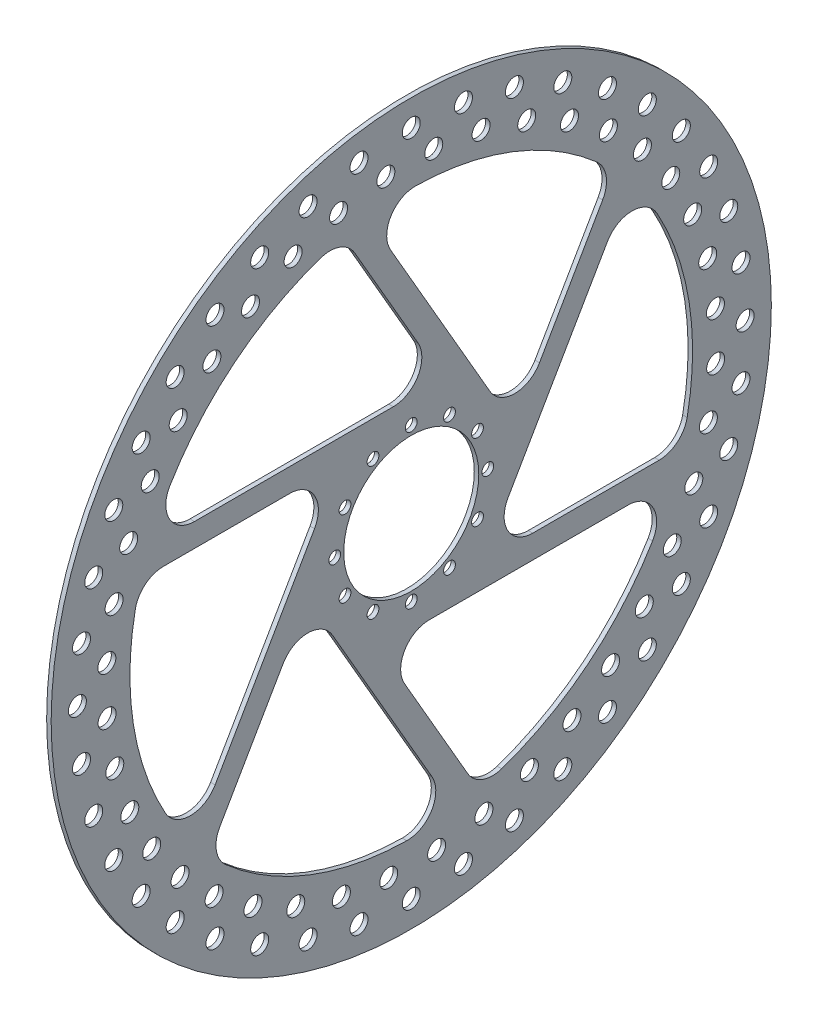
from build123d import *

# Parameters (mm, degrees)
SKETCH1_R           = 160
SKETCH1_R_2         = 4
SKETCH1_R_3         = 2.625
SKETCH1_R_4         = 30
BOSS_EXTRUDE1_DEPTH = 2
FILLET1_R           = 12.7


with BuildPart() as part:
    # Sketch1 → Boss-Extrude1 (new body)
    with BuildSketch(Plane(origin=(0, 0, 0), x_dir=(0, 0, -1), z_dir=(1, 0, 0))):
        Circle(SKETCH1_R)
        with BuildLine():
            Line((-30.068891187, 121.32955857), (14, 45))
            Line((14, 45), (-116.619037897, 45))
            ThreePointArc((-116.619037897, 45), (-82.679426175, 93.750266599), (-30.068891187, 121.32955857))
        make_face(mode=Mode.SUBTRACT)
        with BuildLine():
            Line((45.97114317, 10.375644347), (-19.338375778, 123.495049384))
            ThreePointArc((-19.338375778, 123.495049384), (39.850399399, 118.477616737), (90.040034358, 86.705202917))
            Line((90.040034358, 86.705202917), (45.97114317, 10.375644347))
        make_face(mode=Mode.SUBTRACT)
        with BuildLine():
            Line((31.97114317, -34.624355653), (97.280662119, 78.495049384))
            ThreePointArc((97.280662119, 78.495049384), (122.529825574, 24.727350138), (120.108925545, -34.624355653))
            Line((120.108925545, -34.624355653), (31.97114317, -34.624355653))
        make_face(mode=Mode.SUBTRACT)
        with BuildLine():
            Line((-14, -45), (116.619037897, -45))
            ThreePointArc((116.619037897, -45), (82.679426175, -93.750266599), (30.068891187, -121.32955857))
            Line((30.068891187, -121.32955857), (-14, -45))
        make_face(mode=Mode.SUBTRACT)
        with BuildLine():
            Line((-45.97114317, -10.375644347), (19.338375778, -123.495049384))
            ThreePointArc((19.338375778, -123.495049384), (-39.850399399, -118.477616737), (-90.040034358, -86.705202917))
            Line((-90.040034358, -86.705202917), (-45.97114317, -10.375644347))
        make_face(mode=Mode.SUBTRACT)
        with BuildLine():
            Line((-31.97114317, 34.624355653), (-97.280662119, -78.495049384))
            ThreePointArc((-97.280662119, -78.495049384), (-122.529825574, -24.727350138), (-120.108925545, 34.624355653))
            Line((-120.108925545, 34.624355653), (-31.97114317, 34.624355653))
        make_face(mode=Mode.SUBTRACT)
        with Locations((-87.188145757, -120.004187499)):
            Circle(SKETCH1_R_2, mode=Mode.SUBTRACT)
        with Locations((-120.004187499, -87.188145757)):
            Circle(SKETCH1_R_2, mode=Mode.SUBTRACT)
        with Locations((-104.887505876, -104.887505876)):
            Circle(SKETCH1_R_2, mode=Mode.SUBTRACT)
        with Locations((-87.590662868, -103.545188607)):
            Circle(SKETCH1_R_2, mode=Mode.SUBTRACT)
        with Locations((-102.710312647, -88.568177023)):
            Circle(SKETCH1_R_2, mode=Mode.SUBTRACT)
        with Locations((-45.837520832, -141.07338325)):
            Circle(SKETCH1_R_2, mode=Mode.SUBTRACT)
        with Locations((-67.341924128, -132.165967755)):
            Circle(SKETCH1_R_2, mode=Mode.SUBTRACT)
        with Locations((-51.306447722, -125.54432973)):
            Circle(SKETCH1_R_2, mode=Mode.SUBTRACT)
        with Locations((-23.204445648, -146.507103855)):
            Circle(SKETCH1_R_2, mode=Mode.SUBTRACT)
        with Locations((-31.035320152, -132.024767405)):
            Circle(SKETCH1_R_2, mode=Mode.SUBTRACT)
        with Locations((-10, -135.254317141)):
            Circle(SKETCH1_R_2, mode=Mode.SUBTRACT)
        with Locations((-70.314240273, -115.972574)):
            Circle(SKETCH1_R_2, mode=Mode.SUBTRACT)
        with Locations((-132.165967755, -67.341924128)):
            Circle(SKETCH1_R_2, mode=Mode.SUBTRACT)
        with Locations((-141.07338325, -45.837520832)):
            Circle(SKETCH1_R_2, mode=Mode.SUBTRACT)
        with Locations((-125.052383995, -52.494109789)):
            Circle(SKETCH1_R_2, mode=Mode.SUBTRACT)
        with Locations((-115.300893652, -71.410322981)):
            Circle(SKETCH1_R_2, mode=Mode.SUBTRACT)
        with Locations((-146.507103855, -23.204445648)):
            Circle(SKETCH1_R_2, mode=Mode.SUBTRACT)
        with Locations((-131.724669618, -32.285317396)):
            Circle(SKETCH1_R_2, mode=Mode.SUBTRACT)
        with Locations((-148.333333333, 0)):
            Circle(SKETCH1_R_2, mode=Mode.SUBTRACT)
        with Locations((-135.153456706, -11.28155334)):
            Circle(SKETCH1_R_2, mode=Mode.SUBTRACT)
        with Locations((0, -148.333333333)):
            Circle(SKETCH1_R_2, mode=Mode.SUBTRACT)
        with Locations((23.204445648, -146.507103855)):
            Circle(SKETCH1_R_2, mode=Mode.SUBTRACT)
        with Locations((11.28155334, -135.153456706)):
            Circle(SKETCH1_R_2, mode=Mode.SUBTRACT)
        with Locations((32.285317396, -131.724669618)):
            Circle(SKETCH1_R_2, mode=Mode.SUBTRACT)
        with Locations((45.837520832, -141.07338325)):
            Circle(SKETCH1_R_2, mode=Mode.SUBTRACT)
        with Locations((52.494109789, -125.052383995)):
            Circle(SKETCH1_R_2, mode=Mode.SUBTRACT)
        with Locations((67.341924128, -132.165967755)):
            Circle(SKETCH1_R_2, mode=Mode.SUBTRACT)
        with Locations((71.410322981, -115.300893652)):
            Circle(SKETCH1_R_2, mode=Mode.SUBTRACT)
        with Locations((87.188145757, -120.004187499)):
            Circle(SKETCH1_R_2, mode=Mode.SUBTRACT)
        with Locations((88.568177023, -102.710312647)):
            Circle(SKETCH1_R_2, mode=Mode.SUBTRACT)
        with Locations((104.887505876, -104.887505876)):
            Circle(SKETCH1_R_2, mode=Mode.SUBTRACT)
        with Locations((103.545188607, -87.590662868)):
            Circle(SKETCH1_R_2, mode=Mode.SUBTRACT)
        with Locations((120.004187499, -87.188145757)):
            Circle(SKETCH1_R_2, mode=Mode.SUBTRACT)
        with Locations((115.972574, -70.314240273)):
            Circle(SKETCH1_R_2, mode=Mode.SUBTRACT)
        with Locations((132.165967755, -67.341924128)):
            Circle(SKETCH1_R_2, mode=Mode.SUBTRACT)
        with Locations((125.54432973, -51.306447722)):
            Circle(SKETCH1_R_2, mode=Mode.SUBTRACT)
        with Locations((141.07338325, -45.837520832)):
            Circle(SKETCH1_R_2, mode=Mode.SUBTRACT)
        with Locations((132.024767405, -31.035320152)):
            Circle(SKETCH1_R_2, mode=Mode.SUBTRACT)
        with Locations((146.507103855, -23.204445648)):
            Circle(SKETCH1_R_2, mode=Mode.SUBTRACT)
        with Locations((135.254317141, -10)):
            Circle(SKETCH1_R_2, mode=Mode.SUBTRACT)
        with Locations((-135.254317141, 10)):
            Circle(SKETCH1_R_2, mode=Mode.SUBTRACT)
        with Locations((-146.507103855, 23.204445648)):
            Circle(SKETCH1_R_2, mode=Mode.SUBTRACT)
        with Locations((-132.024767405, 31.035320152)):
            Circle(SKETCH1_R_2, mode=Mode.SUBTRACT)
        with Locations((-141.07338325, 45.837520832)):
            Circle(SKETCH1_R_2, mode=Mode.SUBTRACT)
        with Locations((-125.54432973, 51.306447722)):
            Circle(SKETCH1_R_2, mode=Mode.SUBTRACT)
        with Locations((-132.165967755, 67.341924128)):
            Circle(SKETCH1_R_2, mode=Mode.SUBTRACT)
        with Locations((-115.972574, 70.314240273)):
            Circle(SKETCH1_R_2, mode=Mode.SUBTRACT)
        with Locations((-120.004187499, 87.188145757)):
            Circle(SKETCH1_R_2, mode=Mode.SUBTRACT)
        with Locations((-103.545188607, 87.590662868)):
            Circle(SKETCH1_R_2, mode=Mode.SUBTRACT)
        with Locations((-104.887505876, 104.887505876)):
            Circle(SKETCH1_R_2, mode=Mode.SUBTRACT)
        with Locations((-88.568177023, 102.710312647)):
            Circle(SKETCH1_R_2, mode=Mode.SUBTRACT)
        with Locations((-87.188145757, 120.004187499)):
            Circle(SKETCH1_R_2, mode=Mode.SUBTRACT)
        with Locations((-71.410322981, 115.300893652)):
            Circle(SKETCH1_R_2, mode=Mode.SUBTRACT)
        with Locations((-67.341924128, 132.165967755)):
            Circle(SKETCH1_R_2, mode=Mode.SUBTRACT)
        with Locations((-52.494109789, 125.052383995)):
            Circle(SKETCH1_R_2, mode=Mode.SUBTRACT)
        with Locations((-45.837520832, 141.07338325)):
            Circle(SKETCH1_R_2, mode=Mode.SUBTRACT)
        with Locations((-32.285317396, 131.724669618)):
            Circle(SKETCH1_R_2, mode=Mode.SUBTRACT)
        with Locations((-11.28155334, 135.153456706)):
            Circle(SKETCH1_R_2, mode=Mode.SUBTRACT)
        with Locations((-23.204445648, 146.507103855)):
            Circle(SKETCH1_R_2, mode=Mode.SUBTRACT)
        with Locations((45.837520832, 141.07338325)):
            Circle(SKETCH1_R_2, mode=Mode.SUBTRACT)
        with Locations((102.710312647, 88.568177023)):
            Circle(SKETCH1_R_2, mode=Mode.SUBTRACT)
        with Locations((87.590662868, 103.545188607)):
            Circle(SKETCH1_R_2, mode=Mode.SUBTRACT)
        with Locations((104.887505876, 104.887505876)):
            Circle(SKETCH1_R_2, mode=Mode.SUBTRACT)
        with Locations((120.004187499, 87.188145757)):
            Circle(SKETCH1_R_2, mode=Mode.SUBTRACT)
        with Locations((87.188145757, 120.004187499)):
            Circle(SKETCH1_R_2, mode=Mode.SUBTRACT)
        with Locations((135.153456706, 11.28155334)):
            Circle(SKETCH1_R_2, mode=Mode.SUBTRACT)
        with Locations((148.333333333, 0)):
            Circle(SKETCH1_R_2, mode=Mode.SUBTRACT)
        with Locations((131.724669618, 32.285317396)):
            Circle(SKETCH1_R_2, mode=Mode.SUBTRACT)
        with Locations((146.507103855, 23.204445648)):
            Circle(SKETCH1_R_2, mode=Mode.SUBTRACT)
        with Locations((115.300893652, 71.410322981)):
            Circle(SKETCH1_R_2, mode=Mode.SUBTRACT)
        with Locations((125.052383995, 52.494109789)):
            Circle(SKETCH1_R_2, mode=Mode.SUBTRACT)
        with Locations((141.07338325, 45.837520832)):
            Circle(SKETCH1_R_2, mode=Mode.SUBTRACT)
        with Locations((132.165967755, 67.341924128)):
            Circle(SKETCH1_R_2, mode=Mode.SUBTRACT)
        with Locations((70.314240273, 115.972574)):
            Circle(SKETCH1_R_2, mode=Mode.SUBTRACT)
        with Locations((10, 135.254317141)):
            Circle(SKETCH1_R_2, mode=Mode.SUBTRACT)
        with Locations((31.035320152, 132.024767405)):
            Circle(SKETCH1_R_2, mode=Mode.SUBTRACT)
        with Locations((0, 148.333333333)):
            Circle(SKETCH1_R_2, mode=Mode.SUBTRACT)
        with Locations((23.204445648, 146.507103855)):
            Circle(SKETCH1_R_2, mode=Mode.SUBTRACT)
        with Locations((51.306447722, 125.54432973)):
            Circle(SKETCH1_R_2, mode=Mode.SUBTRACT)
        with Locations((67.341924128, 132.165967755)):
            Circle(SKETCH1_R_2, mode=Mode.SUBTRACT)
        with Locations((0, 34)):
            Circle(SKETCH1_R_3, mode=Mode.SUBTRACT)
        with Locations((-17, -29.444863729)):
            Circle(SKETCH1_R_3, mode=Mode.SUBTRACT)
        with Locations((-29.444863729, -17)):
            Circle(SKETCH1_R_3, mode=Mode.SUBTRACT)
        with Locations((0, -34)):
            Circle(SKETCH1_R_3, mode=Mode.SUBTRACT)
        with Locations((17, -29.444863729)):
            Circle(SKETCH1_R_3, mode=Mode.SUBTRACT)
        with Locations((29.444863729, -17)):
            Circle(SKETCH1_R_3, mode=Mode.SUBTRACT)
        with Locations((-34, 0)):
            Circle(SKETCH1_R_3, mode=Mode.SUBTRACT)
        with Locations((-29.444863729, 17)):
            Circle(SKETCH1_R_3, mode=Mode.SUBTRACT)
        with Locations((-17, 29.444863729)):
            Circle(SKETCH1_R_3, mode=Mode.SUBTRACT)
        Circle(SKETCH1_R_4, mode=Mode.SUBTRACT)
        with Locations((34, 0)):
            Circle(SKETCH1_R_3, mode=Mode.SUBTRACT)
        with Locations((29.444863729, 17)):
            Circle(SKETCH1_R_3, mode=Mode.SUBTRACT)
        with Locations((17, 29.444863729)):
            Circle(SKETCH1_R_3, mode=Mode.SUBTRACT)
    extrude(amount=BOSS_EXTRUDE1_DEPTH)

    # Fillet1
    fillet1_edges = [part.edges().sort_by_distance(p)[0] for p in [
        (1, 10.375644347, -45.97114317),
        (1, 86.705202917, -90.040034358),
        (1, 123.495049384, 19.338375778),
        (1, 78.495049384, -97.280662119),
        (1, -34.624355653, -31.97114317),
        (1, -34.624355653, -120.108925545),
        (1, -45, -116.619037897),
        (1, -45, 14),
        (1, -121.32955857, -30.068891187),
        (1, -123.495049384, -19.338375778),
        (1, -10.375644347, 45.97114317),
        (1, -86.705202917, 90.040034358),
        (1, -78.495049384, 97.280662119),
        (1, 34.624355653, 31.97114317),
        (1, 34.624355653, 120.108925545),
        (1, 45, 116.619037897),
        (1, 45, -14),
        (1, 121.32955857, 30.068891187),
    ]]
    fillet(fillet1_edges, radius=FILLET1_R)


solid = part.part
